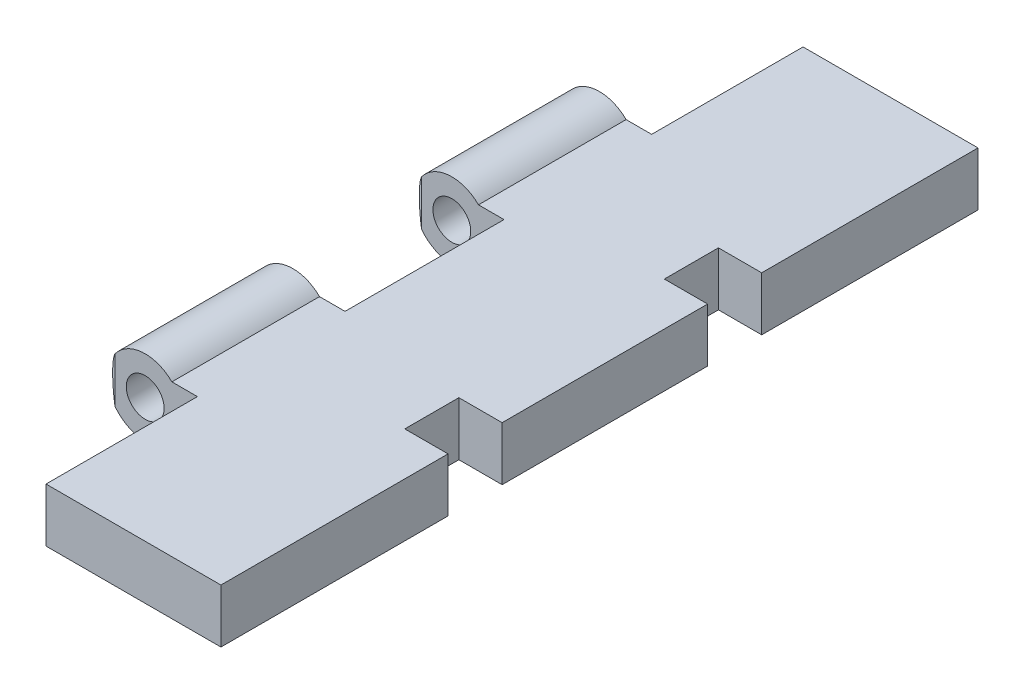
from build123d import *

# Parameters (mm, degrees)
SKETCH5_W                = 30
SKETCH5_H                = 100
BOSS_EXTRUDE2_DEPTH      = 7.1
SKETCH7_W                = 6.895
SKETCH7_H                = 20
SKETCH7_H_2              = 21
CUT_EXTRUDE2_DEPTH       = 140.379819119
SKETCH8_W                = 60
SKETCH8_H                = 5
SPLIT2_SURFACE_1_BACK    = 107.419
SPLIT2_SURFACE_1_DEPTH   = 214.838
SKETCH10_R               = 2.5
CUT_EXTRUDE5_DEPTH       = 20
CUT_EXTRUDE5_DEPTH_BACK  = 67
CUT_EXTRUDE7_DEPTH       = 140.461200617
CUT_EXTRUDE7_DEPTH_BACK  = 140.461200617
SKETCH41_W               = 15.603241914
SKETCH41_H               = 21
CUT_EXTRUDE9_DEPTH       = 140.461200617
CUT_EXTRUDE9_DEPTH_BACK  = 140.461200617
SCALE1_SCALE             = 0.35
SKETCH46_W               = 2
SKETCH46_H               = 3
CUT_EXTRUDE10_DEPTH      = 111.657018213
CUT_EXTRUDE10_DEPTH_BACK = 111.657018213
BOSS_EXTRUDE3_REACH      = 70.762
SKETCH47_W               = 0.5
SKETCH47_H               = 2.485


with BuildPart() as part:
    # Sketch5 → Boss-Extrude2 (new body)
    with BuildSketch(Plane(origin=(0, 0, 0), x_dir=(1, 0, 0), z_dir=(0, 1, 0))):
        with Locations((81.879400831, -49.953517558)):
            Rectangle(SKETCH5_W, SKETCH5_H)
    extrude(amount=BOSS_EXTRUDE2_DEPTH)

    # Sketch7 → Cut-Extrude2 (cut, through all)
    with BuildSketch(Plane(origin=(0, 7.1, 0), x_dir=(1, 0, 0), z_dir=(0, 1, 0))):
        with Locations((70.326900831, -9.953517558)):
            Rectangle(SKETCH7_W, SKETCH7_H)
        with Locations((70.326900831, -49.953517558)):
            Rectangle(SKETCH7_W, SKETCH7_H_2)
        with Locations((70.326900831, -89.953517558)):
            Rectangle(SKETCH7_W, SKETCH7_H)
    extrude(amount=-CUT_EXTRUDE2_DEPTH, mode=Mode.SUBTRACT)

    # Sketch8 → Revolve-Thin2 (revolve)
    with BuildSketch(Plane.ZY.offset(-66.879400831), mode=Mode.PRIVATE) as revolve_thin2_sk:
        with Locations((49.953517558, 6.05)):
            Rectangle(SKETCH8_W, SKETCH8_H)
    revolve(revolve_thin2_sk.sketch.rotate(Axis((66.879400831, 3.55, 19.953517558), (0, 0, 1)), 315.234915329), axis=Axis((66.879400831, 3.55, 19.953517558), (0, 0, 1)))

    # Split2: cut with a surface, the side behind it stays
    # Split2 surface: a surface, the sketch's curves swept straight by 214.838 mm
    with BuildLine(Plane(origin=(0, 7.1, 0), x_dir=(1, 0, 0), z_dir=(0, 1, 0)).offset(-SPLIT2_SURFACE_1_BACK), mode=Mode.PRIVATE) as split2_surface_1_path:
        Line((71.879400831, -39.453517558), (61.879400831, -39.453517558))
        Line((61.879400831, -39.453517558), (61.879400831, -59.953517558))
        Line((61.879400831, -59.953517558), (71.879400831, -59.953517558))
        Line((71.879400831, -59.953517558), (71.879400831, -39.453517558))
    split2_surface_1 = Shell.extrude(split2_surface_1_path.wire(), (0 * SPLIT2_SURFACE_1_DEPTH, 1 * SPLIT2_SURFACE_1_DEPTH, 0 * SPLIT2_SURFACE_1_DEPTH))
    split(bisect_by=split2_surface_1, keep=Keep.BOTTOM)

    # Sketch10 → Cut-Extrude5 (cut, two sides)
    with BuildSketch(Plane.XY.offset(79.953517558)) as cut_extrude5_sk:
        with Locations(Location((66.879400831, 3.55, 0), (0, 0, 180))):
            Circle(SKETCH10_R)
    extrude(amount=CUT_EXTRUDE5_DEPTH, mode=Mode.SUBTRACT)
    extrude(cut_extrude5_sk.sketch, amount=-CUT_EXTRUDE5_DEPTH_BACK, mode=Mode.SUBTRACT)

    # Sketch36 → Cut-Extrude7 (cut, two sides)
    with BuildSketch(Plane(origin=(0, 0, 0), x_dir=(1, 0, 0), z_dir=(0, 1, 0))) as cut_extrude7_sk:
        Polygon((62.879400831, -39.453517558), (61.879400831, -38.753517558), (61.879400831, -39.453517558), align=None)
        Polygon((61.879400831, -59.953517558), (62.879400831, -59.953517558), (61.879400831, -60.653517558), align=None)
        Polygon((62.879400831, -79.953517558), (61.879400831, -79.253517558), (61.879400831, -79.953517558), align=None)
        Polygon((61.879400831, -19.953517558), (62.879400831, -19.953517558), (61.879400831, -20.653517558), align=None)
    extrude(amount=CUT_EXTRUDE7_DEPTH, mode=Mode.SUBTRACT)
    extrude(cut_extrude7_sk.sketch, amount=-CUT_EXTRUDE7_DEPTH_BACK, mode=Mode.SUBTRACT)

    # Sketch41 → Cut-Extrude9 (cut, two sides)
    with BuildSketch(Plane(origin=(0, 7.1, 0), x_dir=(1, 0, 0), z_dir=(0, 1, 0))) as cut_extrude9_sk:
        with Locations((65.972779874, -49.953517558)):
            Rectangle(SKETCH41_W, SKETCH41_H)
    extrude(amount=CUT_EXTRUDE9_DEPTH, mode=Mode.SUBTRACT)
    extrude(cut_extrude9_sk.sketch, amount=-CUT_EXTRUDE9_DEPTH_BACK, mode=Mode.SUBTRACT)


with BuildPart() as part_1:
    # Scale1: scaled about (82.710750678, 3.55, 49.954128315)
    add(part.part.scale(SCALE1_SCALE).moved(Location((53.761987941, 2.3075, 32.470183405))))

    # Sketch46 → Cut-Extrude10 (cut, two sides)
    with BuildSketch(Plane(origin=(0, 4.792503371, 0), x_dir=(1, 0, 0), z_dir=(0, 1, 0))) as cut_extrude10_sk:
        with Locations((86.669801184, -43.953922739)):
            Rectangle(SKETCH46_W, SKETCH46_H)
        with Locations((86.669801184, -55.953922739)):
            Rectangle(SKETCH46_W, SKETCH46_H)
    extrude(amount=CUT_EXTRUDE10_DEPTH, mode=Mode.SUBTRACT)
    extrude(cut_extrude10_sk.sketch, amount=-CUT_EXTRUDE10_DEPTH_BACK, mode=Mode.SUBTRACT)

    # Sketch47 → Boss-Extrude3 (add, up to next)
    with BuildSketch(Plane(origin=(87.669801184, 0, 0), x_dir=(0, 0, -1), z_dir=(1, 0, 0)), mode=Mode.PRIVATE) as boss_extrude3_sk1:
        with Locations((-57.203922739, 3.550003371)):
            Rectangle(SKETCH47_W, SKETCH47_H)
    boss_extrude3_tool1 = extrude(boss_extrude3_sk1.sketch, amount=-BOSS_EXTRUDE3_REACH, mode=Mode.PRIVATE) - part_1.part
    # Sketch47 → Boss-Extrude3 (add, up to next)
    with BuildSketch(Plane(origin=(87.669801184, 0, 0), x_dir=(0, 0, -1), z_dir=(1, 0, 0)), mode=Mode.PRIVATE) as boss_extrude3_sk2:
        with Locations((-45.203922739, 3.550003371)):
            Rectangle(SKETCH47_W, SKETCH47_H)
    boss_extrude3_tool2 = extrude(boss_extrude3_sk2.sketch, amount=-BOSS_EXTRUDE3_REACH, mode=Mode.PRIVATE) - part_1.part
    add(boss_extrude3_tool1.solids().sort_by_distance((87.669801, 3.550003, 57.203923))[0])
    add(boss_extrude3_tool2.solids().sort_by_distance((87.669801, 3.550003, 45.203923))[0])


solid = part_1.part
